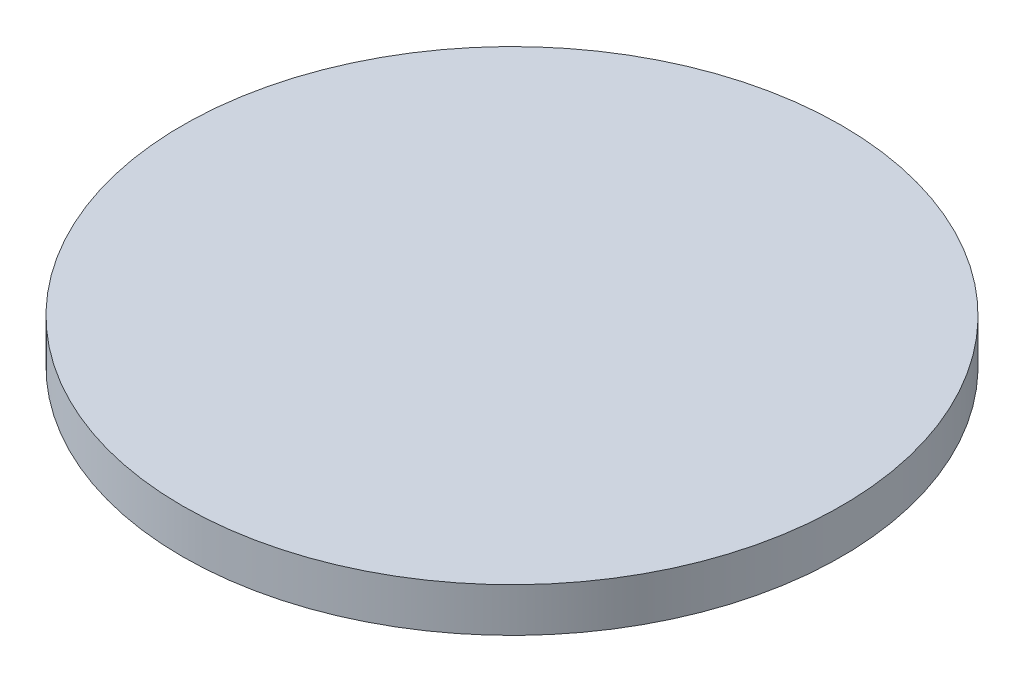
from build123d import *

# Parameters (mm, degrees)
SKETCH1_R           = 15
BOSS_EXTRUDE1_DEPTH = 2


with BuildPart() as part:
    # Sketch1 → Boss-Extrude1 (new body)
    with BuildSketch(Plane(origin=(0, 0, 0), x_dir=(1, 0, 0), z_dir=(0, 1, 0))):
        Circle(SKETCH1_R)
    extrude(amount=BOSS_EXTRUDE1_DEPTH)


solid = part.part
